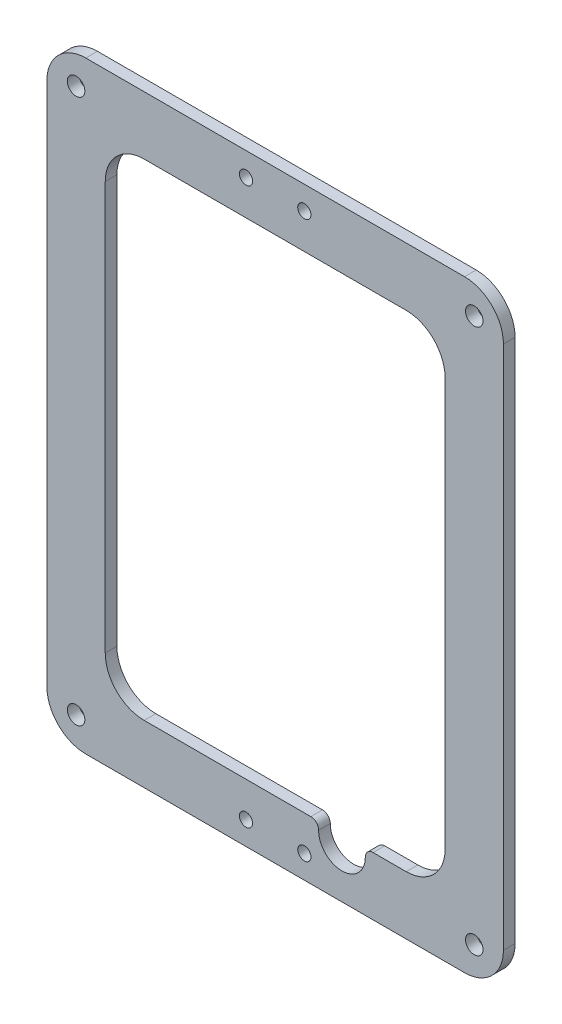
from build123d import *

# Parameters (mm, degrees)
BOSS_EXTRU_1_START = 100
BOSS_EXTRU_1_DEPTH = 3
D_GAGEMENT_M41_D   = 4.5
CONG_1_R           = 2
D_GAGEMENT_M31_D   = 3.4


with BuildPart() as part:
    # Esquisse1 → Boss.-Extru.1 (new body)
    with BuildSketch(Plane.XY.offset(BOSS_EXTRU_1_START)):
        with BuildLine():
            ThreePointArc((-48.696481526, 0), (-55.767549338, -2.928932188), (-58.696481526, -10))
            Line((-58.696481526, -10), (-58.696481526, -145))
            ThreePointArc((-58.696481526, -145), (-55.767549338, -152.071067812), (-48.696481526, -155))
            Line((-48.696481526, -155), (48.696481526, -155))
            ThreePointArc((48.696481526, -155), (55.767549338, -152.071067812), (58.696481526, -145))
            Line((58.696481526, -145), (58.696481526, -10))
            ThreePointArc((58.696481526, -10), (55.767549338, -2.928932188), (48.696481526, 0))
            Line((48.696481526, 0), (-48.696481526, 0))
        make_face()
        with BuildLine():
            Line((-43.696481526, -130), (-43.696481526, -25))
            ThreePointArc((-43.696481526, -25), (-40.767549338, -17.928932188), (-33.696481526, -15))
            Line((-33.696481526, -15), (33.696481526, -15))
            ThreePointArc((33.696481526, -15), (40.767549338, -17.928932188), (43.696481526, -25))
            Line((43.696481526, -25), (43.696481526, -130))
            ThreePointArc((43.696481526, -130), (40.767549338, -137.071067812), (33.696481526, -140))
            Line((33.696481526, -140), (22.797478109, -140))
            ThreePointArc((22.797478109, -140), (23.07986531, -141.030472587), (23.175, -142.094693275))
            ThreePointArc((23.175, -142.094693275), (16.110779311, -147.999558585), (11.552521891, -140))
            Line((11.552521891, -140), (-33.696481526, -140))
            ThreePointArc((-33.696481526, -140), (-40.767549338, -137.071067812), (-43.696481526, -130))
        make_face(mode=Mode.SUBTRACT)
    extrude(amount=BOSS_EXTRU_1_DEPTH)

    # Dégagement M41 (through all)
    with Locations(Plane.XY.offset(103)):
        with Locations((-51.196481526, -7.5), (51.196481526, -7.5), (51.196481526, -147.5), (-51.196481526, -147.5)):
            Hole(D_GAGEMENT_M41_D / 2)

    # Congé1
    cong_1_edges = [part.edges().sort_by_distance(p)[0] for p in [
        (22.797478109, -140, 101.5),
        (11.552521891, -140, 101.5),
    ]]
    fillet(cong_1_edges, radius=CONG_1_R)

    # Dégagement M31 (through all)
    with Locations(Plane.XY.offset(103)):
        with Locations((-7.5, -6), (7.5, -6), (-7.5, -149), (7.5, -149)):
            Hole(D_GAGEMENT_M31_D / 2)


solid = part.part
